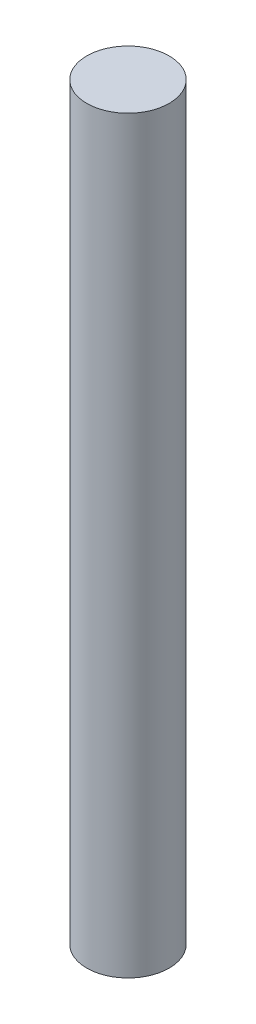
from build123d import *

# Parameters (mm, degrees)
SKETCH1_R           = 2.75
BOSS_EXTRUDE3_DEPTH = 50


with BuildPart() as part:
    # Sketch1 → Boss-Extrude3 (new body)
    with BuildSketch(Plane(origin=(0, 0, 0), x_dir=(1, 0, 0), z_dir=(0, 1, 0))):
        Circle(SKETCH1_R)
    extrude(amount=BOSS_EXTRUDE3_DEPTH)


solid = part.part
